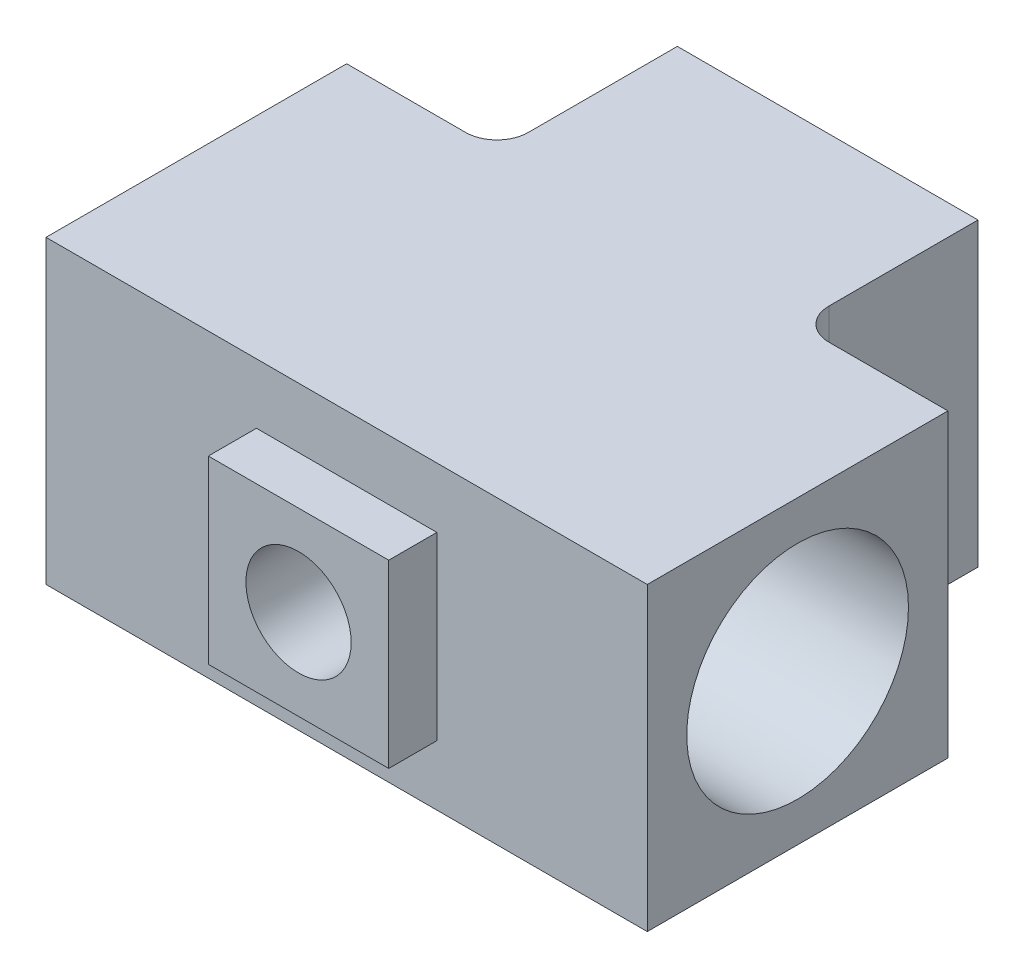
from build123d import *

# Parameters (mm, degrees)
SKETCH2_W                            = 63.5
SKETCH2_H                            = 31.75
SKETCH2_W_2                          = 31.75
SKETCH2_H_2                          = 19.05
BOSS_EXTRUDE1_DEPTH                  = 31.75
F_59_64_0_92188_DIAMETER_HOLE1_D     = 23.415752
F_59_64_0_92188_DIAMETER_HOLE2_D     = 23.415752
F_59_64_0_92188_DIAMETER_HOLE2_DEPTH = 34.29
F_59_64_0_92188_DIAMETER_HOLE2_TIP   = 7.034801621
BOSS_EXTRUDE2_DEPTH                  = 5.08
F_7_16_0_4375_DIAMETER_HOLE1_D       = 11.1125
F_7_16_0_4375_DIAMETER_HOLE1_DEPTH   = 25.4
F_7_16_0_4375_DIAMETER_HOLE1_TIP     = 3.338531814
FILLET1_R                            = 3.302


with BuildPart() as part:
    # Sketch2 → Boss-Extrude1 (new body)
    with BuildSketch(Plane(origin=(0, 0, 0), x_dir=(1, 0, 0), z_dir=(0, 1, 0))):
        Rectangle(SKETCH2_W, SKETCH2_H)
        with Locations((0, 25.4)):
            Rectangle(SKETCH2_W_2, SKETCH2_H_2)
    extrude(amount=BOSS_EXTRUDE1_DEPTH)

    # 59/64 (0.92188) Diameter Hole1 (through all)
    with Locations(Plane(origin=(31.75, 0, 0), x_dir=(0, 0, -1), z_dir=(1, 0, 0))):
        with Locations((0, 15.875)):
            Hole(F_59_64_0_92188_DIAMETER_HOLE1_D / 2)

    # 59/64 (0.92188) Diameter Hole2
    with Locations(Plane(origin=(0, 0, -34.925), x_dir=(-1, 0, 0), z_dir=(0, 0, -1))):
        with Locations((0, 15.875)):
            Hole(F_59_64_0_92188_DIAMETER_HOLE2_D / 2, depth=F_59_64_0_92188_DIAMETER_HOLE2_DEPTH)
            with Locations((0, 0, -(F_59_64_0_92188_DIAMETER_HOLE2_DEPTH + F_59_64_0_92188_DIAMETER_HOLE2_TIP / 2))):  # 118° drill point
                Cone(0, F_59_64_0_92188_DIAMETER_HOLE2_D / 2, F_59_64_0_92188_DIAMETER_HOLE2_TIP, mode=Mode.SUBTRACT)

    # Sketch10 → Boss-Extrude2 (add)
    with BuildSketch(Plane.XY.offset(15.875)):
        Polygon((9.525, 11.1125), (-9.525, 20.6375), (-9.525, 6.35), (9.525, 6.35), align=None)
        Polygon((-9.525, 25.4), (-9.525, 20.6375), (9.525, 11.1125), (9.525, 25.4), align=None)
    extrude(amount=BOSS_EXTRUDE2_DEPTH)

    # 7/16 (0.4375) Diameter Hole1
    with Locations(Plane.XY.offset(20.955)):
        with Locations((0, 15.875)):
            Hole(F_7_16_0_4375_DIAMETER_HOLE1_D / 2, depth=F_7_16_0_4375_DIAMETER_HOLE1_DEPTH)
            with Locations((0, 0, -(F_7_16_0_4375_DIAMETER_HOLE1_DEPTH + F_7_16_0_4375_DIAMETER_HOLE1_TIP / 2))):  # 118° drill point
                Cone(0, F_7_16_0_4375_DIAMETER_HOLE1_D / 2, F_7_16_0_4375_DIAMETER_HOLE1_TIP, mode=Mode.SUBTRACT)

    # Fillet1
    fillet1_edges = [part.edges().sort_by_distance(p)[0] for p in [
        (-15.875, 15.875, -15.875),
        (15.875, 15.875, -15.875),
    ]]
    fillet(fillet1_edges, radius=FILLET1_R)


solid = part.part
